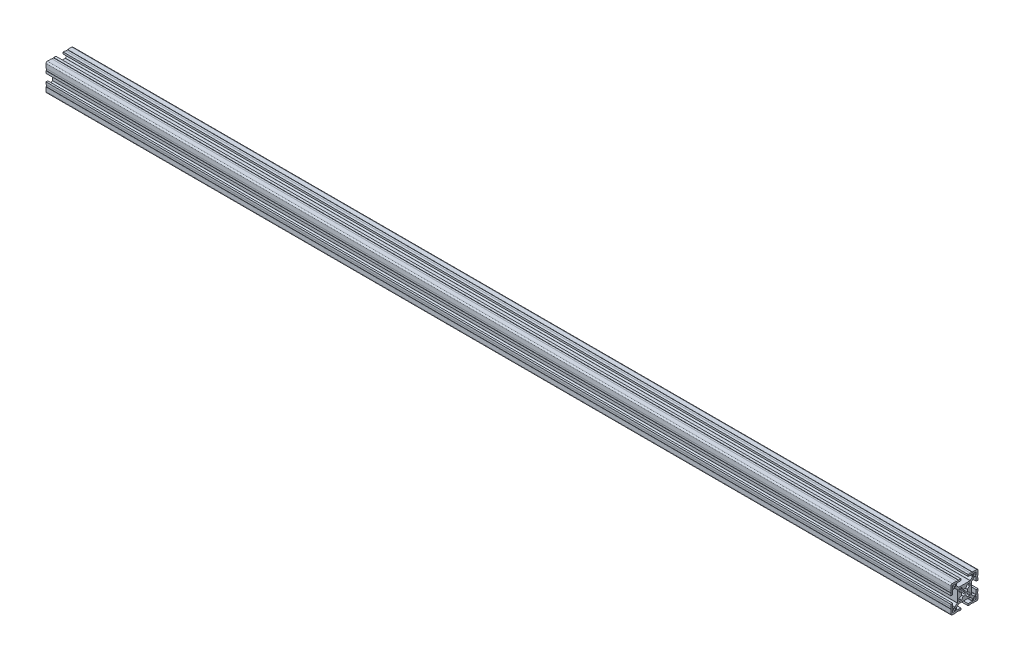
from build123d import *

# Parameters (mm, degrees)
QUADRADO_PF30_11_PERFIL_3030_CENTRO_M8_DEPTH = 1000


with BuildPart() as part:
    # Sketch1 → Quadrado PF30-11 - PERFIL 3030 CENTRO M8(1) (new body)
    with BuildSketch(Plane.YZ):
        with BuildLine():
            Line((14.999995923, 6.599996803), (14.699995923, 6.599996803))
            Line((14.699995923, 6.599996803), (14.699995923, 8.799996803))
            Line((14.699995923, 8.799996803), (14.999995923, 8.799996803))
            Line((14.999995923, 8.799996803), (14.999995923, 13.499995825))
            ThreePointArc((14.999995923, 13.499995825), (14.560656066, 14.560656066), (13.499995825, 14.999995923))
            Line((13.499995825, 14.999995923), (8.799996818, 14.999995923))
            Line((8.799996818, 14.999995923), (8.799996818, 14.699995923))
            Line((8.799996818, 14.699995923), (6.599996818, 14.699995923))
            Line((6.599996818, 14.699995923), (6.599996818, 14.999995923))
            Line((6.599996818, 14.999995923), (4.0499987, 14.999995923))
            Line((4.0499987, 14.999995923), (4.0499987, 12.999995366))
            Line((4.0499987, 12.999995366), (8.699997649, 12.999995366))
            ThreePointArc((8.699997649, 12.999995366), (8.912129683, 12.9121274), (8.999997649, 12.699995366))
            Line((8.999997649, 12.699995366), (8.999997649, 10.679894006))
            ThreePointArc((8.999997649, 10.679894006), (8.977161511, 10.565088981), (8.912129691, 10.467761979))
            Line((8.912129691, 10.467761979), (6.432230191, 7.987862303))
            ThreePointArc((6.432230191, 7.987862303), (6.334903184, 7.922830472), (6.220098149, 7.89999433))
            Line((6.220098149, 7.89999433), (-6.220098149, 7.89999433))
            ThreePointArc((-6.220098149, 7.89999433), (-6.334903184, 7.922830472), (-6.432230191, 7.987862303))
            Line((-6.432230191, 7.987862303), (-8.912129691, 10.467761979))
            ThreePointArc((-8.912129691, 10.467761979), (-8.977161511, 10.565088981), (-8.999997649, 10.679894006))
            Line((-8.999997649, 10.679894006), (-8.999997649, 12.699995366))
            ThreePointArc((-8.999997649, 12.699995366), (-8.912129683, 12.9121274), (-8.699997649, 12.999995366))
            Line((-8.699997649, 12.999995366), (-4.0499987, 12.999995366))
            Line((-4.0499987, 12.999995366), (-4.0499987, 14.999995923))
            Line((-4.0499987, 14.999995923), (-6.599996818, 14.999995923))
            Line((-6.599996818, 14.999995923), (-6.599996818, 14.699995923))
            Line((-6.599996818, 14.699995923), (-8.799996818, 14.699995923))
            Line((-8.799996818, 14.699995923), (-8.799996818, 14.999995923))
            Line((-8.799996818, 14.999995923), (-13.499995825, 14.999995923))
            ThreePointArc((-13.499995825, 14.999995923), (-14.560656066, 14.560656066), (-14.999995923, 13.499995825))
            Line((-14.999995923, 13.499995825), (-14.999995923, 8.799996803))
            Line((-14.999995923, 8.799996803), (-14.699995923, 8.799996803))
            Line((-14.699995923, 8.799996803), (-14.699995923, 6.599996803))
            Line((-14.699995923, 6.599996803), (-14.999995923, 6.599996803))
            Line((-14.999995923, 6.599996803), (-14.999995923, 4.0499987))
            Line((-14.999995923, 4.0499987), (-12.999995366, 4.0499987))
            Line((-12.999995366, 4.0499987), (-12.999995366, 8.699997649))
            ThreePointArc((-12.999995366, 8.699997649), (-12.9121274, 8.912129683), (-12.699995366, 8.999997649))
            Line((-12.699995366, 8.999997649), (-10.679894006, 8.999997649))
            ThreePointArc((-10.679894006, 8.999997649), (-10.565088981, 8.977161511), (-10.467761979, 8.912129691))
            Line((-10.467761979, 8.912129691), (-7.987862303, 6.432230191))
            ThreePointArc((-7.987862303, 6.432230191), (-7.922830472, 6.334903184), (-7.89999433, 6.220098149))
            Line((-7.89999433, 6.220098149), (-7.89999433, -6.220098149))
            ThreePointArc((-7.89999433, -6.220098149), (-7.922830472, -6.334903184), (-7.987862303, -6.432230191))
            Line((-7.987862303, -6.432230191), (-10.467761979, -8.912129691))
            ThreePointArc((-10.467761979, -8.912129691), (-10.565088981, -8.977161511), (-10.679894006, -8.999997649))
            Line((-10.679894006, -8.999997649), (-12.699995366, -8.999997649))
            ThreePointArc((-12.699995366, -8.999997649), (-12.9121274, -8.912129683), (-12.999995366, -8.699997649))
            Line((-12.999995366, -8.699997649), (-12.999995366, -4.0499987))
            Line((-12.999995366, -4.0499987), (-14.999995923, -4.0499987))
            Line((-14.999995923, -4.0499987), (-14.999995923, -6.599996803))
            Line((-14.999995923, -6.599996803), (-14.699995923, -6.599996803))
            Line((-14.699995923, -6.599996803), (-14.699995923, -8.799996803))
            Line((-14.699995923, -8.799996803), (-14.999995923, -8.799996803))
            Line((-14.999995923, -8.799996803), (-14.999995923, -13.499995825))
            ThreePointArc((-14.999995923, -13.499995825), (-14.560656066, -14.560656066), (-13.499995825, -14.999995923))
            Line((-13.499995825, -14.999995923), (-8.799996818, -14.999995923))
            Line((-8.799996818, -14.999995923), (-8.799996818, -14.699995923))
            Line((-8.799996818, -14.699995923), (-6.599996818, -14.699995923))
            Line((-6.599996818, -14.699995923), (-6.599996818, -14.999995923))
            Line((-6.599996818, -14.999995923), (-4.0499987, -14.999995923))
            Line((-4.0499987, -14.999995923), (-4.0499987, -12.999995366))
            Line((-4.0499987, -12.999995366), (-8.699997649, -12.999995366))
            ThreePointArc((-8.699997649, -12.999995366), (-8.912129683, -12.9121274), (-8.999997649, -12.699995366))
            Line((-8.999997649, -12.699995366), (-8.999997649, -10.679894006))
            ThreePointArc((-8.999997649, -10.679894006), (-8.977161511, -10.565088981), (-8.912129691, -10.467761979))
            Line((-8.912129691, -10.467761979), (-6.432230191, -7.987862303))
            ThreePointArc((-6.432230191, -7.987862303), (-6.334903184, -7.922830472), (-6.220098149, -7.89999433))
            Line((-6.220098149, -7.89999433), (6.220098149, -7.89999433))
            ThreePointArc((6.220098149, -7.89999433), (6.334903184, -7.922830472), (6.432230191, -7.987862303))
            Line((6.432230191, -7.987862303), (8.912129691, -10.467761979))
            ThreePointArc((8.912129691, -10.467761979), (8.977161511, -10.565088981), (8.999997649, -10.679894006))
            Line((8.999997649, -10.679894006), (8.999997649, -12.699995366))
            ThreePointArc((8.999997649, -12.699995366), (8.912129683, -12.9121274), (8.699997649, -12.999995366))
            Line((8.699997649, -12.999995366), (4.0499987, -12.999995366))
            Line((4.0499987, -12.999995366), (4.0499987, -14.999995923))
            Line((4.0499987, -14.999995923), (6.599996818, -14.999995923))
            Line((6.599996818, -14.999995923), (6.599996818, -14.699995923))
            Line((6.599996818, -14.699995923), (8.799996818, -14.699995923))
            Line((8.799996818, -14.699995923), (8.799996818, -14.999995923))
            Line((8.799996818, -14.999995923), (13.499995825, -14.999995923))
            ThreePointArc((13.499995825, -14.999995923), (14.560656066, -14.560656066), (14.999995923, -13.499995825))
            Line((14.999995923, -13.499995825), (14.999995923, -8.799996803))
            Line((14.999995923, -8.799996803), (14.699995923, -8.799996803))
            Line((14.699995923, -8.799996803), (14.699995923, -6.599996803))
            Line((14.699995923, -6.599996803), (14.999995923, -6.599996803))
            Line((14.999995923, -6.599996803), (14.999995923, -4.0499987))
            Line((14.999995923, -4.0499987), (12.999995366, -4.0499987))
            Line((12.999995366, -4.0499987), (12.999995366, -8.699997649))
            ThreePointArc((12.999995366, -8.699997649), (12.9121274, -8.912129683), (12.699995366, -8.999997649))
            Line((12.699995366, -8.999997649), (10.679894006, -8.999997649))
            ThreePointArc((10.679894006, -8.999997649), (10.565088981, -8.977161511), (10.467761979, -8.912129691))
            Line((10.467761979, -8.912129691), (7.987862303, -6.432230191))
            ThreePointArc((7.987862303, -6.432230191), (7.922830472, -6.334903184), (7.89999433, -6.220098149))
            Line((7.89999433, -6.220098149), (7.89999433, 6.220098149))
            ThreePointArc((7.89999433, 6.220098149), (7.922830472, 6.334903184), (7.987862303, 6.432230191))
            Line((7.987862303, 6.432230191), (10.467761979, 8.912129691))
            ThreePointArc((10.467761979, 8.912129691), (10.565088981, 8.977161511), (10.679894006, 8.999997649))
            Line((10.679894006, 8.999997649), (12.699995366, 8.999997649))
            ThreePointArc((12.699995366, 8.999997649), (12.9121274, 8.912129683), (12.999995366, 8.699997649))
            Line((12.999995366, 8.699997649), (12.999995366, 4.0499987))
            Line((12.999995366, 4.0499987), (14.999995923, 4.0499987))
            Line((14.999995923, 4.0499987), (14.999995923, 6.599996803))
        make_face()
        with BuildLine():
            Line((-6.1, -3.425408784), (-6.1, -5.6))
            ThreePointArc((-6.1, -5.6), (-5.953553391, -5.953553391), (-5.6, -6.1))
            Line((-5.6, -6.1), (-3.425408784, -6.1))
            ThreePointArc((-3.425408784, -6.1), (-3.175408784, -6.033012702), (-2.992396082, -5.85))
            Line((-2.992396082, -5.85), (-1.402974441, -3.097040962))
            ThreePointArc((-1.402974441, -3.097040962), (0, -3.4), (1.402974441, -3.097040962))
            Line((1.402974441, -3.097040962), (2.992396082, -5.85))
            ThreePointArc((2.992396082, -5.85), (3.175408784, -6.033012702), (3.425408784, -6.1))
            Line((3.425408784, -6.1), (5.6, -6.1))
            ThreePointArc((5.6, -6.1), (5.953553391, -5.953553391), (6.1, -5.6))
            Line((6.1, -5.6), (6.1, -3.425408784))
            ThreePointArc((6.1, -3.425408784), (6.033012702, -3.175408784), (5.85, -2.992396082))
            Line((5.85, -2.992396082), (3.097040962, -1.402974441))
            ThreePointArc((3.097040962, -1.402974441), (3.4, 0), (3.097040962, 1.402974441))
            Line((3.097040962, 1.402974441), (5.85, 2.992396082))
            ThreePointArc((5.85, 2.992396082), (6.033012702, 3.175408784), (6.1, 3.425408784))
            Line((6.1, 3.425408784), (6.1, 5.6))
            ThreePointArc((6.1, 5.6), (5.953553391, 5.953553391), (5.6, 6.1))
            Line((5.6, 6.1), (3.425408784, 6.1))
            ThreePointArc((3.425408784, 6.1), (3.175408784, 6.033012702), (2.992396082, 5.85))
            Line((2.992396082, 5.85), (1.402974441, 3.097040962))
            ThreePointArc((1.402974441, 3.097040962), (0, 3.4), (-1.402974441, 3.097040962))
            Line((-1.402974441, 3.097040962), (-2.992396082, 5.85))
            ThreePointArc((-2.992396082, 5.85), (-3.175408784, 6.033012702), (-3.425408784, 6.1))
            Line((-3.425408784, 6.1), (-5.6, 6.1))
            ThreePointArc((-5.6, 6.1), (-5.953553391, 5.953553391), (-6.1, 5.6))
            Line((-6.1, 5.6), (-6.1, 3.425408784))
            ThreePointArc((-6.1, 3.425408784), (-6.033012702, 3.175408784), (-5.85, 2.992396082))
            Line((-5.85, 2.992396082), (-3.097040962, 1.402974441))
            ThreePointArc((-3.097040962, 1.402974441), (-3.4, 0), (-3.097040962, -1.402974441))
            Line((-3.097040962, -1.402974441), (-5.85, -2.992396082))
            ThreePointArc((-5.85, -2.992396082), (-6.033012702, -3.175408784), (-6.1, -3.425408784))
        make_face(mode=Mode.SUBTRACT)
        with BuildLine():
            Line((9.999995366, 12.699997649), (9.999995366, 10.299997649))
            ThreePointArc((9.999995366, 10.299997649), (10.087863331, 10.087865615), (10.299995366, 9.999997649))
            Line((10.299995366, 9.999997649), (12.699995366, 9.999997649))
            ThreePointArc((12.699995366, 9.999997649), (12.9121274, 10.087865615), (12.999995366, 10.299997649))
            Line((12.999995366, 10.299997649), (12.999995366, 12.699997649))
            ThreePointArc((12.999995366, 12.699997649), (12.9121274, 12.912129683), (12.699995366, 12.999997649))
            Line((12.699995366, 12.999997649), (10.299995366, 12.999997649))
            ThreePointArc((10.299995366, 12.999997649), (10.087863331, 12.912129683), (9.999995366, 12.699997649))
        make_face(mode=Mode.SUBTRACT)
        with BuildLine():
            Line((12.999995366, -12.699997649), (12.999995366, -10.299997649))
            ThreePointArc((12.999995366, -10.299997649), (12.9121274, -10.087865615), (12.699995366, -9.999997649))
            Line((12.699995366, -9.999997649), (10.299995366, -9.999997649))
            ThreePointArc((10.299995366, -9.999997649), (10.087863331, -10.087865615), (9.999995366, -10.299997649))
            Line((9.999995366, -10.299997649), (9.999995366, -12.699997649))
            ThreePointArc((9.999995366, -12.699997649), (10.087863331, -12.912129683), (10.299995366, -12.999997649))
            Line((10.299995366, -12.999997649), (12.699995366, -12.999997649))
            ThreePointArc((12.699995366, -12.999997649), (12.9121274, -12.912129683), (12.999995366, -12.699997649))
        make_face(mode=Mode.SUBTRACT)
        with BuildLine():
            Line((-10.299995366, -9.999997649), (-12.699995366, -9.999997649))
            ThreePointArc((-12.699995366, -9.999997649), (-12.9121274, -10.087865615), (-12.999995366, -10.299997649))
            Line((-12.999995366, -10.299997649), (-12.999995366, -12.699997649))
            ThreePointArc((-12.999995366, -12.699997649), (-12.9121274, -12.912129683), (-12.699995366, -12.999997649))
            Line((-12.699995366, -12.999997649), (-10.299995366, -12.999997649))
            ThreePointArc((-10.299995366, -12.999997649), (-10.087863331, -12.912129683), (-9.999995366, -12.699997649))
            Line((-9.999995366, -12.699997649), (-9.999995366, -10.299997649))
            ThreePointArc((-9.999995366, -10.299997649), (-10.087863331, -10.087865615), (-10.299995366, -9.999997649))
        make_face(mode=Mode.SUBTRACT)
        with BuildLine():
            Line((-12.999995366, 12.699997649), (-12.999995366, 10.299997649))
            ThreePointArc((-12.999995366, 10.299997649), (-12.9121274, 10.087865615), (-12.699995366, 9.999997649))
            Line((-12.699995366, 9.999997649), (-10.299995366, 9.999997649))
            ThreePointArc((-10.299995366, 9.999997649), (-10.087863331, 10.087865615), (-9.999995366, 10.299997649))
            Line((-9.999995366, 10.299997649), (-9.999995366, 12.699997649))
            ThreePointArc((-9.999995366, 12.699997649), (-10.087863331, 12.912129683), (-10.299995366, 12.999997649))
            Line((-10.299995366, 12.999997649), (-12.699995366, 12.999997649))
            ThreePointArc((-12.699995366, 12.999997649), (-12.9121274, 12.912129683), (-12.999995366, 12.699997649))
        make_face(mode=Mode.SUBTRACT)
    extrude(amount=QUADRADO_PF30_11_PERFIL_3030_CENTRO_M8_DEPTH)


solid = part.part
